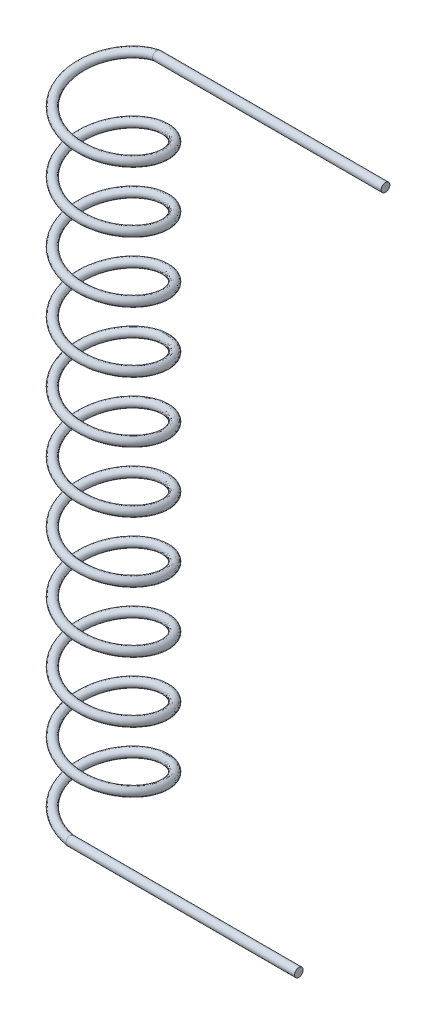
from build123d import *

# Parameters (mm, degrees)
SWEEP1_PITCH        = 35
SWEEP1_HEIGHT       = 367.5
SWEEP1_RADIUS       = 25
SKETCH5_R           = 2.5
SKETCH6_R           = 2.5
BOSS_EXTRUDE1_DEPTH = 132


with BuildPart() as part:
    # Sweep1: sweep along a helix
    with BuildLine() as sweep1_path:
        Helix(SWEEP1_PITCH, SWEEP1_HEIGHT, SWEEP1_RADIUS, center=(0, 0, 0), direction=(0, 1, 0), lefthand=True)
    # Sketch5 → Sweep1 (sweep)
    with BuildSketch(Plane(origin=(0, 0, 0), x_dir=(0, 0, -1), z_dir=(1, 0, 0))):
        with Locations((-25, 0)):
            Circle(SKETCH5_R)
    sweep(path=sweep1_path.line, is_frenet=True)

    # Sketch6 → Boss-Extrude1 (add)
    with BuildSketch(Plane(origin=(0, 0, 0), x_dir=(0, 0, -1), z_dir=(1, 0, 0))):
        with Locations((25, 367.5)):
            Circle(SKETCH6_R)
        with Locations((-25, 0)):
            Circle(SKETCH6_R)
    extrude(amount=BOSS_EXTRUDE1_DEPTH)


solid = part.part
